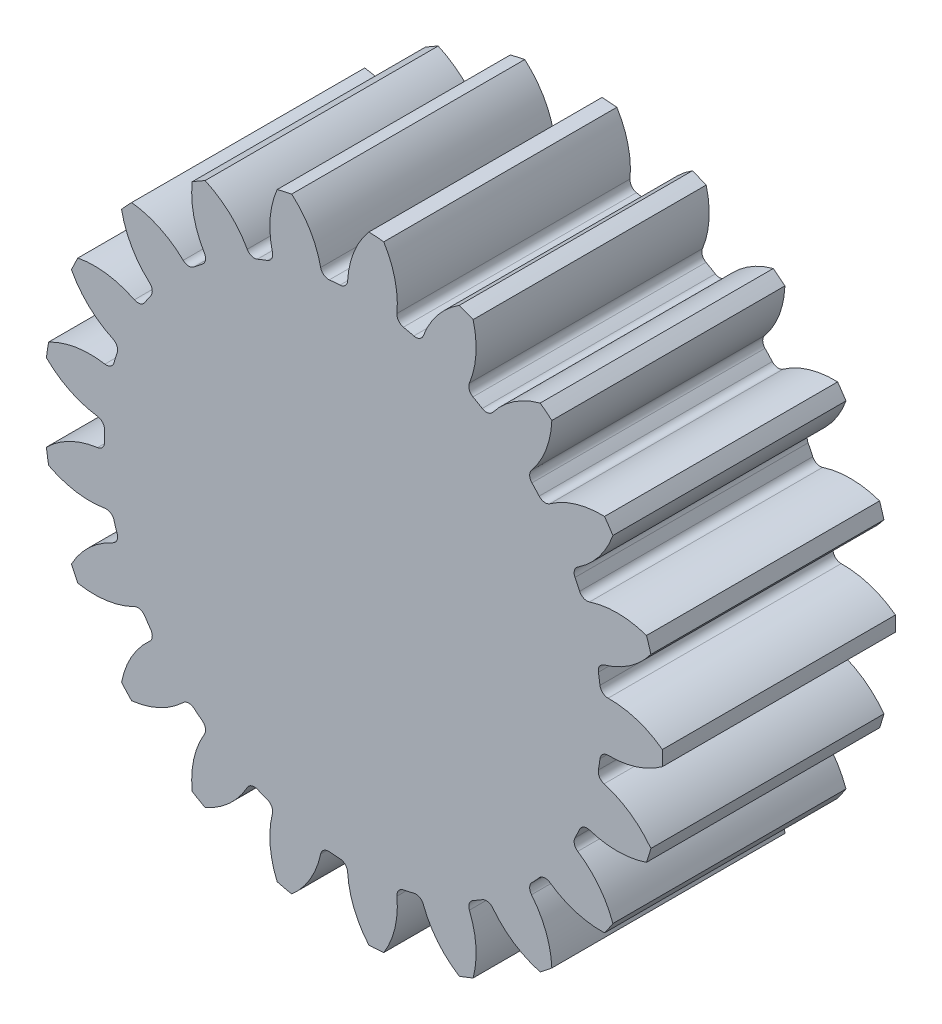
from build123d import *

# Parameters (mm, degrees)
SKETCH1_R                = 34.5
BOSS_EXTRUDE1_DEPTH      = 13
CUT_EXTRUDE1_DEPTH       = 14
FILLET1_R                = 0.9
CIRPATTERN1_COUNT        = 21
FILLET1_OF_CIRPATTERN1_R = 0.9


with BuildPart() as part:
    # Sketch1 → Boss-Extrude1 (new body, symmetric)
    with BuildSketch(Plane.XY):
        Circle(SKETCH1_R)
    extrude(amount=BOSS_EXTRUDE1_DEPTH, both=True)

    # Sketch4 → Cut-Extrude1 (cut, symmetric)
    with BuildSketch(Plane.XY):
        with BuildLine():
            ThreePointArc((-35.100552185, -5.310483621), (-31.831811789, -2.561944644), (-27.712969906, -1.43310815))
            ThreePointArc((-27.712969906, -1.43310815), (-27.75, 0), (-27.712969906, 1.43310815))
            ThreePointArc((-27.712969906, 1.43310815), (-31.831811789, 2.561944644), (-35.100552185, 5.310483621))
            ThreePointArc((-35.100552185, 5.310483621), (-35.5, 0), (-35.100552185, -5.310483621))
        make_face()
    cut_extrude1 = extrude(amount=CUT_EXTRUDE1_DEPTH, both=True, mode=Mode.SUBTRACT)

    # Fillet1
    fillet1_edges = [part.edges().sort_by_distance(p)[0] for p in [
        (-27.712969906, -1.43310815, 0),
        (-27.712969906, 1.43310815, 0),
    ]]
    fillet(fillet1_edges, radius=FILLET1_R)

    # CirPattern1: Cut-Extrude1 ×21 about axis
    cirpattern1_axis = Axis((0, 0, 0), (0, 0, 1))
    for i in range(1, CIRPATTERN1_COUNT):
        add(cut_extrude1.rotate(cirpattern1_axis, i * 360 / CIRPATTERN1_COUNT), mode=Mode.SUBTRACT)

    # Fillet1 of CirPattern1
    fillet1_of_cirpattern1_edges = [part.edges().sort_by_distance(p)[0] for p in [
        (-26.059344367, -9.537980454, 0),
        (-26.904176453, -6.799102102, 0),
        (-22.090231722, -16.795361338, 0),
        (-23.704828855, -14.427182295, 0),
        (-16.158305046, -22.560400662, 0),
        (-18.399203186, -20.773344029, 0),
        (-8.790642058, -26.320849382, 0),
        (-11.45872757, -25.273702983, 0),
        (-0.641891945, -27.742575128, 0),
        (-3.500093724, -27.528382516, 0),
        (7.563893083, -26.699251327, 0),
        (4.769538809, -27.337044455, 0),
        (15.097593018, -23.283581878, 0),
        (12.615376889, -24.716690028, 0),
        (21.289805558, -17.799064001, 0),
        (19.34028337, -19.900149225, 0),
        (25.590325446, -10.733021177, 0),
        (24.3467208, -13.315392833, 0),
        (27.617032616, -2.713302321, 0),
        (27.189845243, -5.547505354, 0),
        (27.189845243, 5.547505354, 0),
        (27.617032616, 2.713302321, 0),
        (24.3467208, 13.315392833, 0),
        (25.590325446, 10.733021177, 0),
        (19.34028337, 19.900149225, 0),
        (21.289805558, 17.799064001, 0),
        (12.615376889, 24.716690028, 0),
        (15.097593018, 23.283581878, 0),
        (4.769538809, 27.337044455, 0),
        (7.563893083, 26.699251327, 0),
        (-3.500093724, 27.528382516, 0),
        (-0.641891945, 27.742575128, 0),
        (-11.45872757, 25.273702983, 0),
        (-8.790642058, 26.320849382, 0),
        (-18.399203186, 20.773344029, 0),
        (-16.158305046, 22.560400662, 0),
        (-23.704828855, 14.427182295, 0),
        (-22.090231722, 16.795361338, 0),
        (-26.904176453, 6.799102102, 0),
        (-26.059344367, 9.537980454, 0),
    ]]
    fillet(fillet1_of_cirpattern1_edges, radius=FILLET1_OF_CIRPATTERN1_R)


solid = part.part
